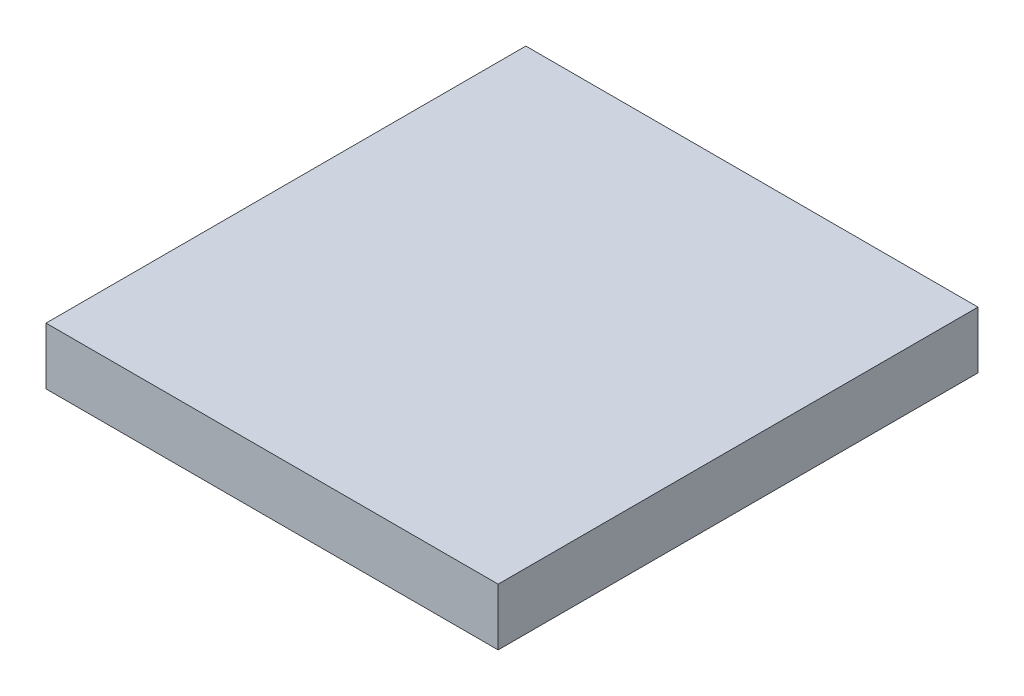
from build123d import *

# Parameters (mm, degrees)
SKETCH_1_W      = 238
SKETCH_1_H      = 252.580549317
EXTRUDE_1_DEPTH = 30


with BuildPart() as part:
    # Эскиз1 → Бобышка-Вытянуть1 (new body)
    with BuildSketch(Plane(origin=(0, 0, 0), x_dir=(1, 0, 0), z_dir=(0, 1, 0))):
        with Locations((119, 126.290274659)):
            Rectangle(SKETCH_1_W, SKETCH_1_H)
    extrude(amount=EXTRUDE_1_DEPTH)


solid = part.part
